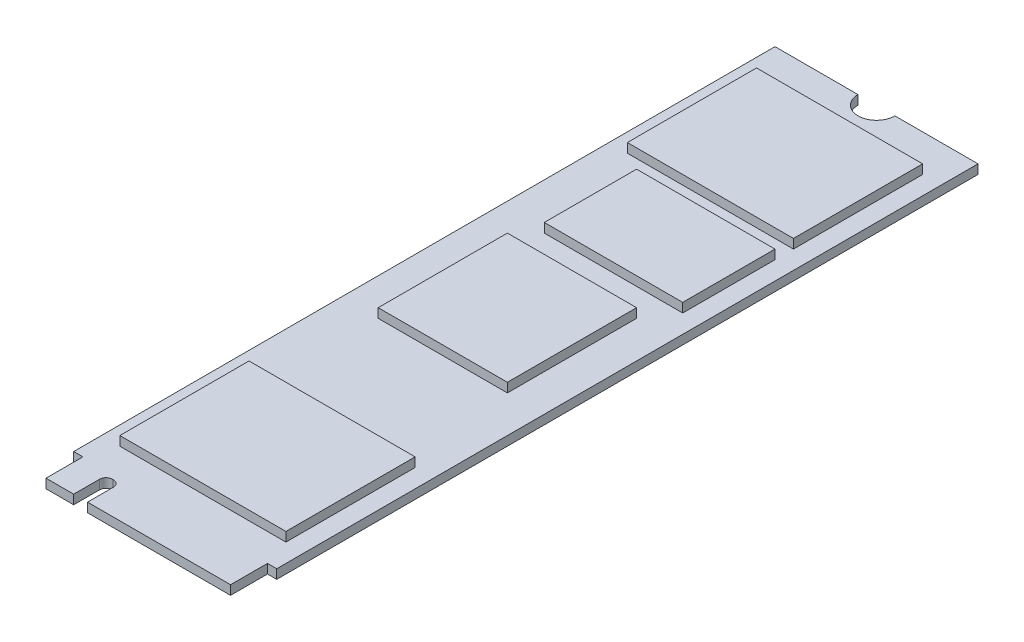
from build123d import *

# Parameters (mm, degrees)
BOSS_EXTRUDE1_DEPTH = 1
SKETCH2_R           = 2
CUT_EXTRUDE1_DEPTH  = 2
SKETCH4_W           = 18
SKETCH4_H           = 14
SKETCH4_W_2         = 15
SKETCH4_H_2         = 10
SKETCH4_W_3         = 14
BOSS_EXTRUDE2_DEPTH = 1


with BuildPart() as part:
    # Sketch1 → Boss-Extrude1 (new body)
    with BuildSketch(Plane(origin=(0, 0, 0), x_dir=(1, 0, 0), z_dir=(0, 1, 0))):
        with BuildLine():
            Line((11, 40), (-11, 40))
            Line((-11, 40), (-11, -36))
            Line((-11, -36), (-10, -36))
            Line((-10, -36), (-10, -40))
            Line((-10, -40), (-7, -40))
            Line((-7, -40), (-7, -37.2))
            ThreePointArc((-7, -37.2), (-6.794974747, -36.705025253), (-6.3, -36.5))
            Line((-6.3, -36.5), (-6.2, -36.5))
            ThreePointArc((-6.2, -36.5), (-5.705025253, -36.705025253), (-5.5, -37.2))
            Line((-5.5, -37.2), (-5.5, -40))
            Line((-5.5, -40), (10, -40))
            Line((10, -40), (10, -36))
            Line((10, -36), (11, -36))
            Line((11, -36), (11, 40))
        make_face()
    extrude(amount=BOSS_EXTRUDE1_DEPTH)

    # Sketch2 → Cut-Extrude1 (cut, through all)
    with BuildSketch(Plane(origin=(0, 1, 0), x_dir=(1, 0, 0), z_dir=(0, 1, 0))):
        with Locations((0, 40)):
            Circle(SKETCH2_R)
    extrude(amount=-CUT_EXTRUDE1_DEPTH, mode=Mode.SUBTRACT)

    # Sketch4 → Boss-Extrude2 (add)
    with BuildSketch(Plane(origin=(0, 1, 0), x_dir=(1, 0, 0), z_dir=(0, 1, 0))):
        with Locations((0, 29)):
            Rectangle(SKETCH4_W, SKETCH4_H)
        with Locations((1.5, 15)):
            Rectangle(SKETCH4_W_2, SKETCH4_H_2)
        Rectangle(SKETCH4_W_3, SKETCH4_H)
        with Locations((0, -26)):
            Rectangle(SKETCH4_W, SKETCH4_H)
    extrude(amount=BOSS_EXTRUDE2_DEPTH)


solid = part.part
